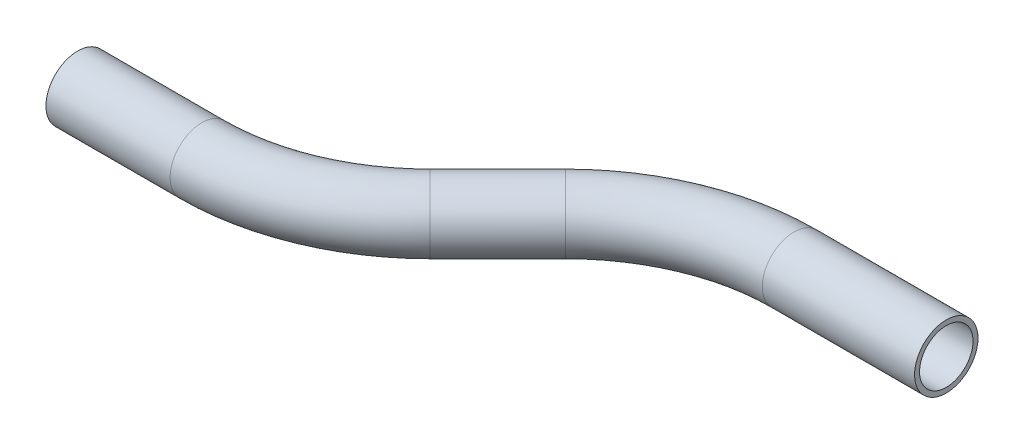
from build123d import *

# Parameters (mm, degrees)
SKETCH2_R   = 7.9375
SKETCH2_R_2 = 6.6929


with BuildPart() as part:
    # Sweep1: sweep along a path in Sketch1
    with BuildLine(Plane(origin=(0, 0, 0), x_dir=(1, 0, 0), z_dir=(0, 1, 0))) as sweep1_path:
        Line((0, 0), (31.066352514, 0))
        ThreePointArc((31.066352514, 0), (52.936710674, 4.350284717), (71.477505059, 16.738847455))
        Line((71.477505059, 16.738847455), (88.415939949, 33.677282345))
        ThreePointArc((88.415939949, 33.677282345), (106.956734334, 46.065845083), (128.827092494, 50.4161298))
        Line((128.827092494, 50.4161298), (166.927092494, 50.4161298))
    # Sketch2 → Sweep1 (sweep)
    with BuildSketch(Plane(origin=(0, 0, 0), x_dir=(0, 0, -1), z_dir=(1, 0, 0))):
        Circle(SKETCH2_R)
        Circle(SKETCH2_R_2, mode=Mode.SUBTRACT)
    sweep(path=sweep1_path.line)


solid = part.part
